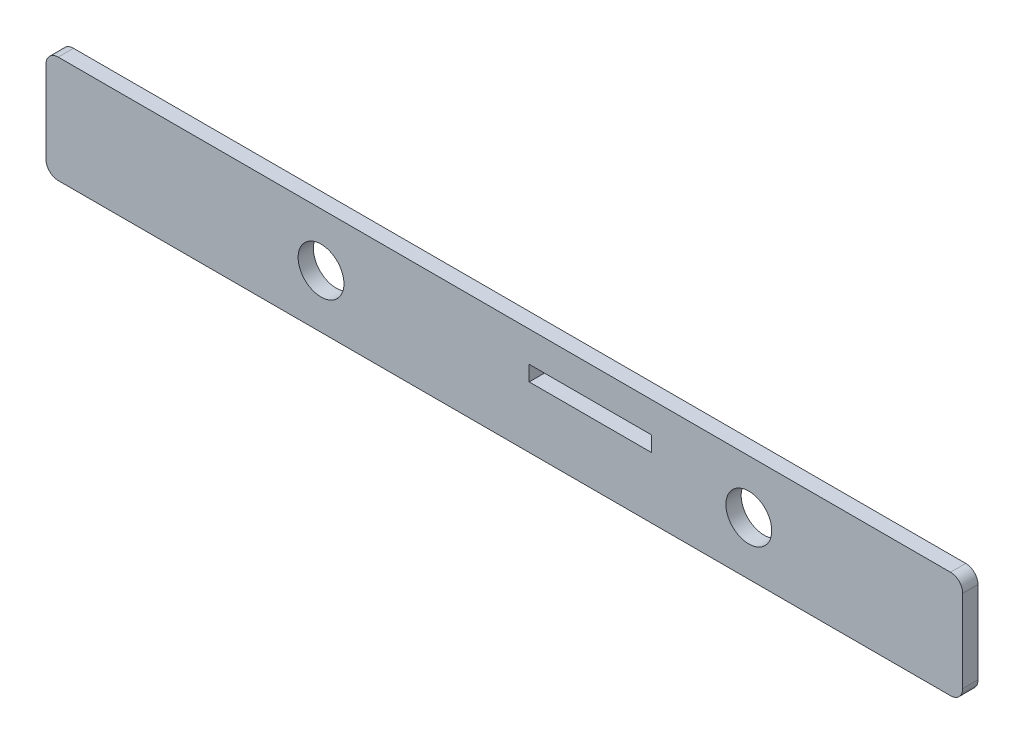
from build123d import *

# Parameters (mm, degrees)
SKETCH1_W           = 381
SKETCH1_H           = 44.45
SKETCH1_R           = 9.525
BOSS_EXTRUDE1_DEPTH = 6.35
FILLET1_R           = 5.08
SKETCH2_W           = 50.8
SKETCH2_H           = 6.35
CUT_EXTRUDE1_DEPTH  = 7.35


with BuildPart() as part:
    # Sketch1 → Boss-Extrude1 (new body)
    with BuildSketch(Plane.XY):
        with Locations((1295.4, -50.8)):
            Rectangle(SKETCH1_W, SKETCH1_H)
        with Locations((1219.2, -50.8)):
            Circle(SKETCH1_R, mode=Mode.SUBTRACT)
        with Locations((1397, -50.8)):
            Circle(SKETCH1_R, mode=Mode.SUBTRACT)
    extrude(amount=BOSS_EXTRUDE1_DEPTH)

    # Fillet1
    fillet1_edges = [part.edges().sort_by_distance(p)[0] for p in [
        (1104.9, -28.575, 3.175),
        (1485.9, -28.575, 3.175),
        (1485.9, -73.025, 3.175),
        (1104.9, -73.025, 3.175),
    ]]
    fillet(fillet1_edges, radius=FILLET1_R)

    # Sketch2 → Cut-Extrude1 (cut, through all)
    with BuildSketch(Plane.XY.offset(6.35)):
        with Locations((1331.11875, -44.45)):
            Rectangle(SKETCH2_W, SKETCH2_H)
    extrude(amount=-CUT_EXTRUDE1_DEPTH, mode=Mode.SUBTRACT)


solid = part.part
